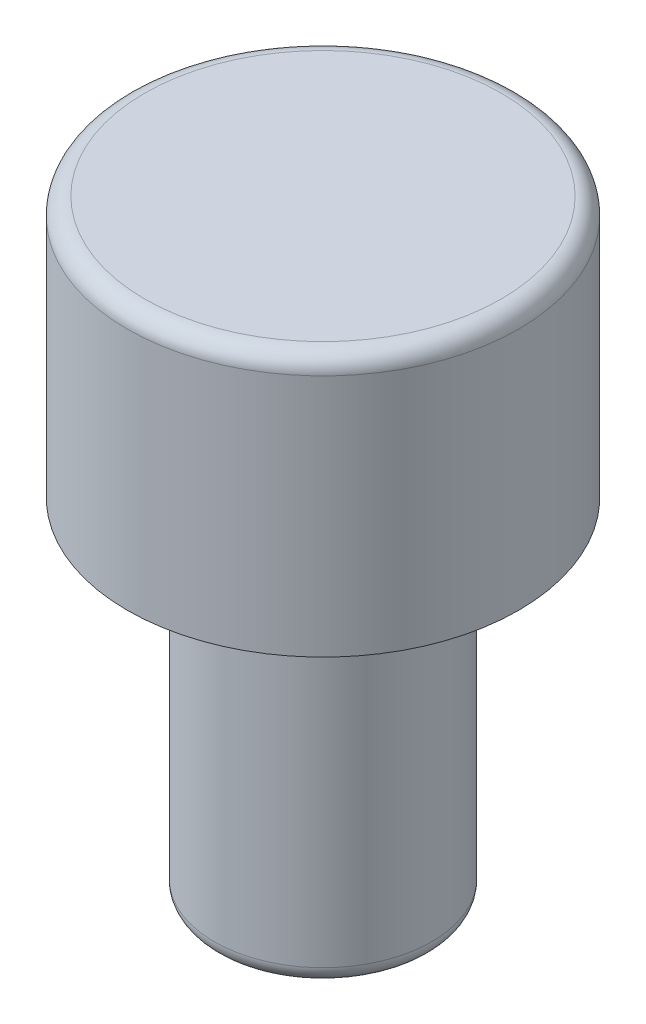
from build123d import *

# Parameters (mm, degrees)
SKETCH1_W   = 2.25
SKETCH1_H   = 3
SKETCH1_W_2 = 1.25
SKETCH1_H_2 = 4
FILLET1_R   = 0.2
FILLET2_R   = 0.2


with BuildPart() as part:
    # Sketch1 → Revolve1 (revolve)
    with BuildSketch(Plane.XY):
        with Locations((1.125, 1.5)):
            Rectangle(SKETCH1_W, SKETCH1_H)
        with Locations((0.625, -2)):
            Rectangle(SKETCH1_W_2, SKETCH1_H_2)
    revolve(axis=Axis((0, 0, 0), (0, -1, 0)))

    # Fillet1
    fillet1_edges = [part.edges().sort_by_distance(p)[0] for p in [
        (-2.25, 3, 0),
    ]]
    fillet(fillet1_edges, radius=FILLET1_R)

    # Fillet2
    fillet2_edges = [part.edges().sort_by_distance(p)[0] for p in [
        (-1.25, -4, 0),
    ]]
    fillet(fillet2_edges, radius=FILLET2_R)


solid = part.part
